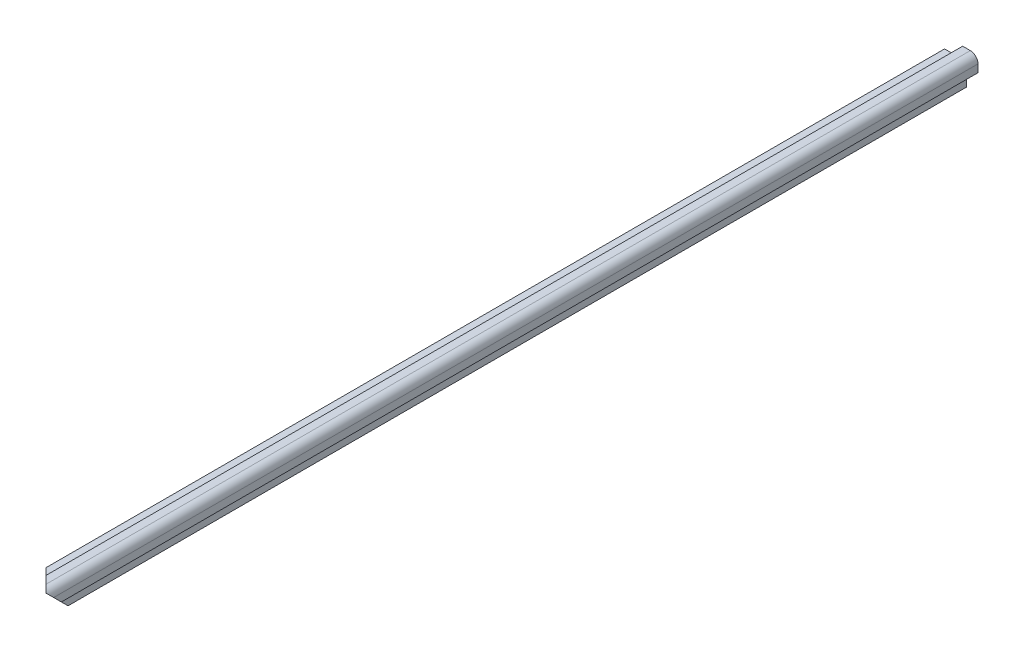
from build123d import *

# Parameters (mm, degrees)
SKETCH7_W               = 4.7625
SKETCH7_H               = 2.12122512
BOSS_EXTRUDE2_DEPTH     = 130.175
SKETCH8_W               = 2.12122512
SKETCH8_H               = 4.7625
BOSS_EXTRUDE3_DEPTH     = 130.175
BOSS_EXTRUDE4_DEPTH     = 130.175
CUT_EXTRUDE1_DEPTH      = 150.236313895
CUT_EXTRUDE1_DEPTH_BACK = 12.241080233


with BuildPart() as part:
    # Sketch7 → Boss-Extrude2 (new body, symmetric)
    with BuildSketch(Plane.XY):
        with Locations((-4.92125, -2.560612608)):
            Rectangle(SKETCH7_W, SKETCH7_H)
    extrude(amount=BOSS_EXTRUDE2_DEPTH, both=True)

    # Sketch8 → Boss-Extrude3 (add, symmetric)
    with BuildSketch(Plane.XY):
        with Locations((-2.560612608, -4.92125)):
            Rectangle(SKETCH8_W, SKETCH8_H)
    extrude(amount=BOSS_EXTRUDE3_DEPTH, both=True)

    # Sketch11 → Boss-Extrude4 (add, symmetric)
    with BuildSketch(Plane.XY):
        with BuildLine():
            Line((-2.54, 1.500000048), (-2.54, -1.500000048))
            Line((-2.54, -1.500000048), (-7.3025, -1.500000048))
            Line((-7.3025, -1.500000048), (-7.3025, -3.621225168))
            Line((-7.3025, -3.621225168), (-5.866289198, -3.621225168))
            Line((-5.866289198, -3.621225168), (-3.621225168, -5.866289198))
            Line((-3.621225168, -5.866289198), (-3.621225168, -7.3025))
            Line((-3.621225168, -7.3025), (-1.500000048, -7.3025))
            Line((-1.500000048, -7.3025), (-1.500000048, -2.54))
            Line((-1.500000048, -2.54), (1.500000048, -2.54))
            Line((1.500000048, -2.54), (1.500000048, -0.519999976))
            ThreePointArc((1.500000048, -0.519999976), (0.908355739, 0.908355739), (-0.519999976, 1.500000048))
            Line((-0.519999976, 1.500000048), (-2.54, 1.500000048))
        make_face()
    extrude(amount=BOSS_EXTRUDE4_DEPTH, both=True)

    # Sketch17 → Cut-Extrude1 (cut, two sides)
    with BuildSketch(Plane(origin=(0, 0, 113.704878), x_dir=(0.707106781, 0, -0.707106781), z_dir=(-0.577350269, -0.577350269, -0.577350269))) as cut_extrude1_sk:
        Polygon((9.347296833, 5.396664343), (0, 0), (0, -10.793328686), (-219.970452561, 116.206671314), (-210.623155728, 132.396664343), align=None)
    extrude(amount=CUT_EXTRUDE1_DEPTH, mode=Mode.SUBTRACT)
    extrude(cut_extrude1_sk.sketch, amount=-CUT_EXTRUDE1_DEPTH_BACK, mode=Mode.SUBTRACT)


solid = part.part
